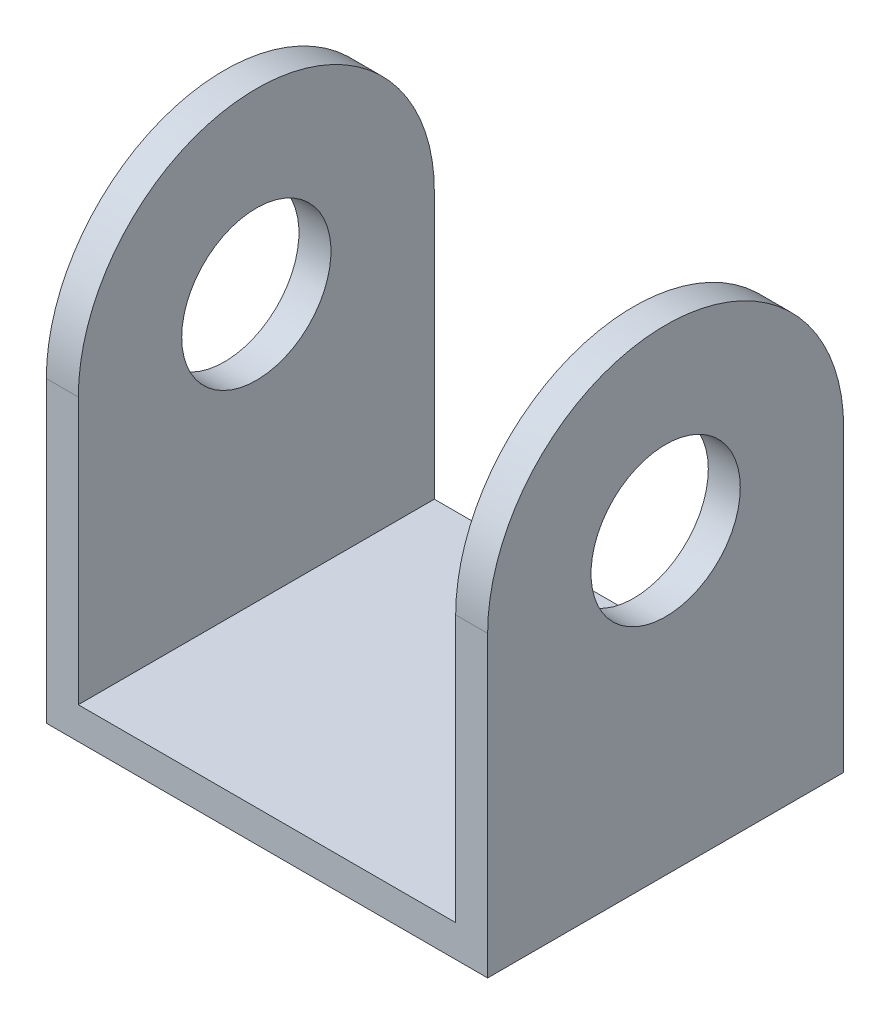
from build123d import *

# Parameters (mm, degrees)
CROQUIS1_R              = 7.000000002
SALIENTE_EXTRUIR1_DEPTH = 3
CROQUIS2_W              = 33.4
CROQUIS2_H              = 3
SALIENTE_EXTRUIR2_DEPTH = 41.4
CROQUIS3_R              = 7.000000002
SALIENTE_EXTRUIR3_DEPTH = 3


with BuildPart() as part:
    # Croquis1 → Saliente-Extruir1 (new body)
    with BuildSketch(Plane(origin=(0, 0, 0), x_dir=(0, 0, -1), z_dir=(1, 0, 0))):
        with BuildLine():
            Line((16.7, 25), (16.7, 0))
            Line((16.7, 0), (-16.7, 0))
            Line((-16.7, 0), (-16.7, 25))
            ThreePointArc((-16.7, 25), (0, 41.7), (16.7, 25))
        make_face()
        with Locations((0, 25)):
            Circle(CROQUIS1_R, mode=Mode.SUBTRACT)
    extrude(amount=SALIENTE_EXTRUIR1_DEPTH)

    # Croquis2 → Saliente-Extruir2 (add)
    with BuildSketch(Plane(origin=(3, 0, 0), x_dir=(0, 0, -1), z_dir=(1, 0, 0))):
        with Locations((0, -1.5)):
            Rectangle(CROQUIS2_W, CROQUIS2_H)
    extrude(amount=-SALIENTE_EXTRUIR2_DEPTH)

    # Croquis3 → Saliente-Extruir3 (add)
    with BuildSketch(Plane.ZY.offset(38.4)):
        with BuildLine():
            Line((16.7, 0), (16.7, 25))
            ThreePointArc((16.7, 25), (0, 41.7), (-16.7, 25))
            Line((-16.7, 25), (-16.7, 0))
            Line((-16.7, 0), (16.7, 0))
        make_face()
        with Locations((0, 25)):
            Circle(CROQUIS3_R, mode=Mode.SUBTRACT)
    extrude(amount=-SALIENTE_EXTRUIR3_DEPTH)


solid = part.part
